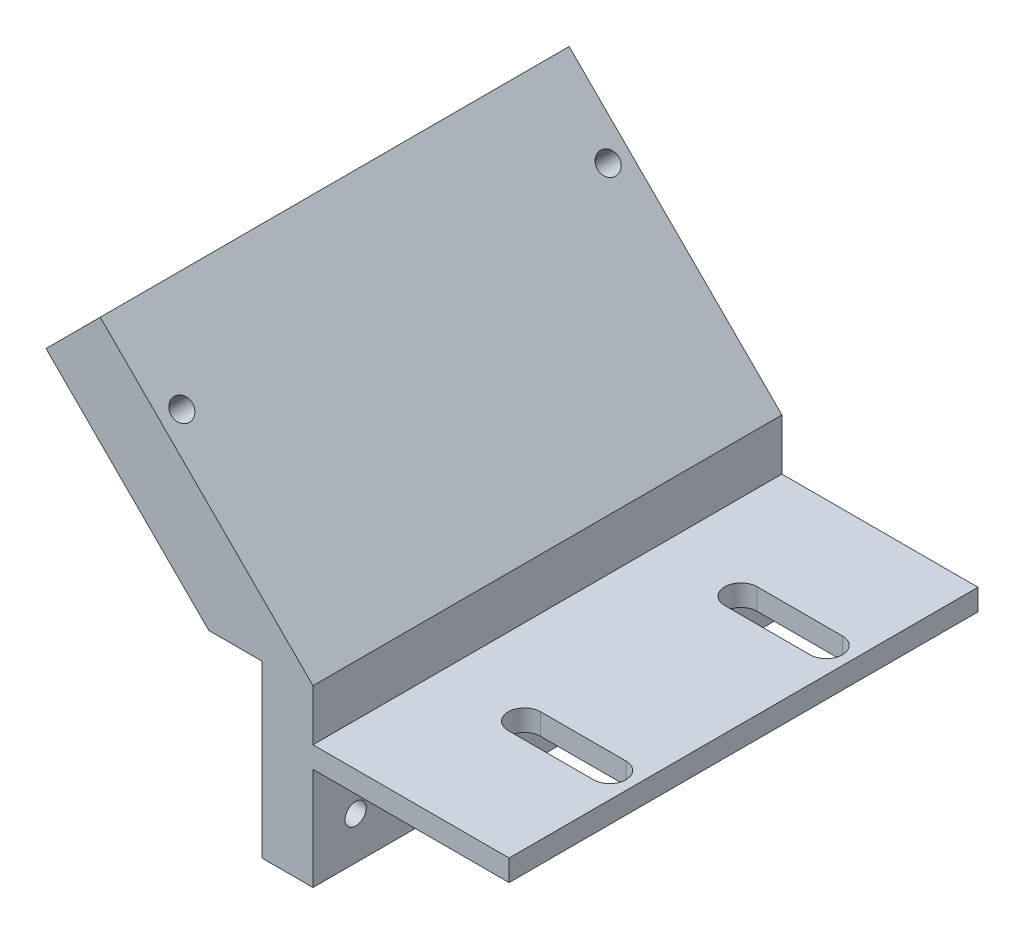
from build123d import *

# Parameters (mm, degrees)
BOSS_EXTRUDE1_DEPTH = 27.5
CUT_EXTRUDE2_REACH  = 16.5
CUT_EXTRUDE3_REACH  = 33.32
SKETCH4_R           = 1.25
CUT_EXTRUDE4_REACH  = 38.642
SKETCH5_R           = 1.25


with BuildPart() as part:
    # Sketch1 → Boss-Extrude1 (new body, symmetric)
    with BuildSketch(Plane.XY):
        Polygon((0, 0), (-23, 0), (-23, -12), (-29, -12), (-29, 8), (-35.227922061, 8), (-54.319805153, 27.091883092), (-47.955844123, 33.455844123), (-23, 8.5), (-23, 2.5), (0, 2.5), align=None)
    extrude(amount=BOSS_EXTRUDE1_DEPTH, both=True)

    # Sketch3 → Cut-Extrude2 (cut, up to next)
    with BuildSketch(Plane(origin=(0, 2.5, 0), x_dir=(1, 0, 0), z_dir=(0, 1, 0)), mode=Mode.PRIVATE) as cut_extrude2_sk1:
        with BuildLine():
            Line((-13, -10.795), (-3, -10.795))
            ThreePointArc((-3, -10.795), (-1.095, -12.7), (-3, -14.605))
            Line((-3, -14.605), (-13, -14.605))
            ThreePointArc((-13, -14.605), (-14.905, -12.7), (-13, -10.795))
        make_face()
    cut_extrude2_tool1 = extrude(cut_extrude2_sk1.sketch, amount=-CUT_EXTRUDE2_REACH, mode=Mode.PRIVATE) & part.part
    add(cut_extrude2_tool1.solids().sort_by_distance((-8, 2.5, 12.7))[0], mode=Mode.SUBTRACT)
    # Sketch3 → Cut-Extrude2 (cut, up to next)
    with BuildSketch(Plane(origin=(0, 2.5, 0), x_dir=(1, 0, 0), z_dir=(0, 1, 0)), mode=Mode.PRIVATE) as cut_extrude2_sk2:
        with BuildLine():
            Line((-13, 10.795), (-3, 10.795))
            ThreePointArc((-3, 10.795), (-1.095, 12.7), (-3, 14.605))
            Line((-3, 14.605), (-13, 14.605))
            ThreePointArc((-13, 14.605), (-14.905, 12.7), (-13, 10.795))
        make_face()
    cut_extrude2_tool2 = extrude(cut_extrude2_sk2.sketch, amount=-CUT_EXTRUDE2_REACH, mode=Mode.PRIVATE) & part.part
    add(cut_extrude2_tool2.solids().sort_by_distance((-8, 2.5, -12.7))[0], mode=Mode.SUBTRACT)

    # Sketch4 → Cut-Extrude3 (cut, up to next)
    with BuildSketch(Plane(origin=(-23, 0, 0), x_dir=(0, 0, -1), z_dir=(1, 0, 0)), mode=Mode.PRIVATE) as cut_extrude3_sk1:
        with Locations((-22.5, -7)):
            Circle(SKETCH4_R)
    cut_extrude3_tool1 = extrude(cut_extrude3_sk1.sketch, amount=-CUT_EXTRUDE3_REACH, mode=Mode.PRIVATE) & part.part
    add(cut_extrude3_tool1.solids().sort_by_distance((-23, -7, 22.5))[0], mode=Mode.SUBTRACT)
    # Sketch4 → Cut-Extrude3 (cut, up to next)
    with BuildSketch(Plane(origin=(-23, 0, 0), x_dir=(0, 0, -1), z_dir=(1, 0, 0)), mode=Mode.PRIVATE) as cut_extrude3_sk2:
        with Locations((22.5, -7)):
            Circle(SKETCH4_R)
    cut_extrude3_tool2 = extrude(cut_extrude3_sk2.sketch, amount=-CUT_EXTRUDE3_REACH, mode=Mode.PRIVATE) & part.part
    add(cut_extrude3_tool2.solids().sort_by_distance((-23, -7, -22.5))[0], mode=Mode.SUBTRACT)

    # Sketch5 → Cut-Extrude4 (cut, up to next)
    with BuildSketch(Plane(origin=(-7.25, -7.25, 0), x_dir=(0, 0, -1), z_dir=(0.707106781, 0.707106781, 0)), mode=Mode.PRIVATE) as cut_extrude4_sk1:
        with Locations((-25, 47.566756826)):
            Circle(SKETCH5_R)
    cut_extrude4_tool1 = extrude(cut_extrude4_sk1.sketch, amount=-CUT_EXTRUDE4_REACH, mode=Mode.PRIVATE) & part.part
    add(cut_extrude4_tool1.solids().sort_by_distance((-40.884776, 26.384776, 25))[0], mode=Mode.SUBTRACT)
    # Sketch5 → Cut-Extrude4 (cut, up to next)
    with BuildSketch(Plane(origin=(-7.25, -7.25, 0), x_dir=(0, 0, -1), z_dir=(0.707106781, 0.707106781, 0)), mode=Mode.PRIVATE) as cut_extrude4_sk2:
        with Locations((25, 47.566756826)):
            Circle(SKETCH5_R)
    cut_extrude4_tool2 = extrude(cut_extrude4_sk2.sketch, amount=-CUT_EXTRUDE4_REACH, mode=Mode.PRIVATE) & part.part
    add(cut_extrude4_tool2.solids().sort_by_distance((-40.884776, 26.384776, -25))[0], mode=Mode.SUBTRACT)


solid = part.part
